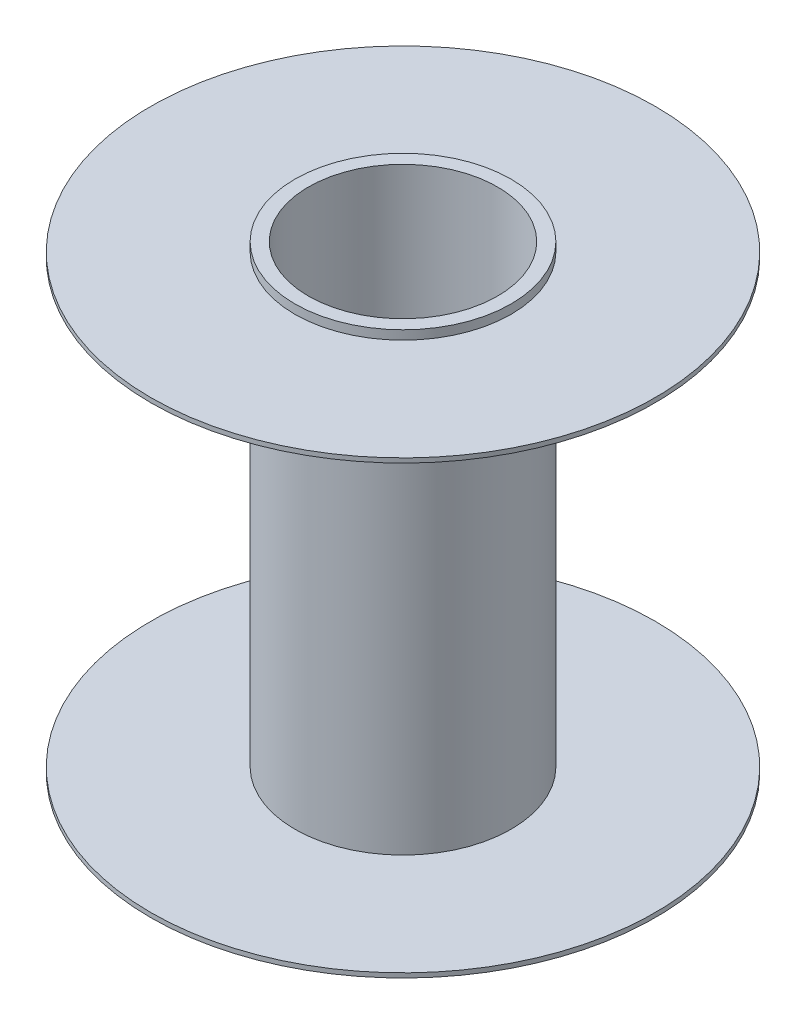
from build123d import *

# Parameters (mm, degrees)
CROQUIS1_R              = 2.4
CROQUIS1_R_2            = 2.1
SALIENTE_EXTRUIR1_DEPTH = 0.2
CROQUIS3_R              = 5.6
CROQUIS3_R_2            = 2.3
SALIENTE_EXTRUIR2_DEPTH = 0.1
CROQUIS5_R              = 2.4
CROQUIS5_R_2            = 2.1
SALIENTE_EXTRUIR3_DEPTH = 5


with BuildPart() as part:
    # Croquis1 → Saliente-Extruir1 (new body)
    with BuildSketch(Plane(origin=(0, 0, 0), x_dir=(1, 0, 0), z_dir=(0, 1, 0))):
        Circle(CROQUIS1_R)
        Circle(CROQUIS1_R_2, mode=Mode.SUBTRACT)
    saliente_extruir1 = extrude(amount=SALIENTE_EXTRUIR1_DEPTH)



with BuildPart() as body_2:
    # Croquis3 → Saliente-Extruir2 (new body)
    with BuildSketch(Plane.XZ):
        Circle(CROQUIS3_R)
        Circle(CROQUIS3_R_2, mode=Mode.SUBTRACT)
    saliente_extruir2 = extrude(amount=SALIENTE_EXTRUIR2_DEPTH)


with BuildPart() as part_1:
    add(part.part)

    add(body_2.part)  # Saliente-Extruir3 merges body 2
    # Croquis5 → Saliente-Extruir3 (add)
    with BuildSketch(Plane.XZ):
        Circle(CROQUIS5_R)
        Circle(CROQUIS5_R_2, mode=Mode.SUBTRACT)
    saliente_extruir3 = extrude(amount=SALIENTE_EXTRUIR3_DEPTH)

    # Simetría2: Saliente-Extruir1, Saliente-Extruir2, Saliente-Extruir3 across plane
    add(saliente_extruir1.mirror(Plane(origin=(0, -5, 0), x_dir=(0, 0, 1), z_dir=(0, -1, 0))))
    add(saliente_extruir2.mirror(Plane(origin=(0, -5, 0), x_dir=(0, 0, 1), z_dir=(0, -1, 0))))
    add(saliente_extruir3.mirror(Plane(origin=(0, -5, 0), x_dir=(0, 0, 1), z_dir=(0, -1, 0))))


solid = part_1.part
